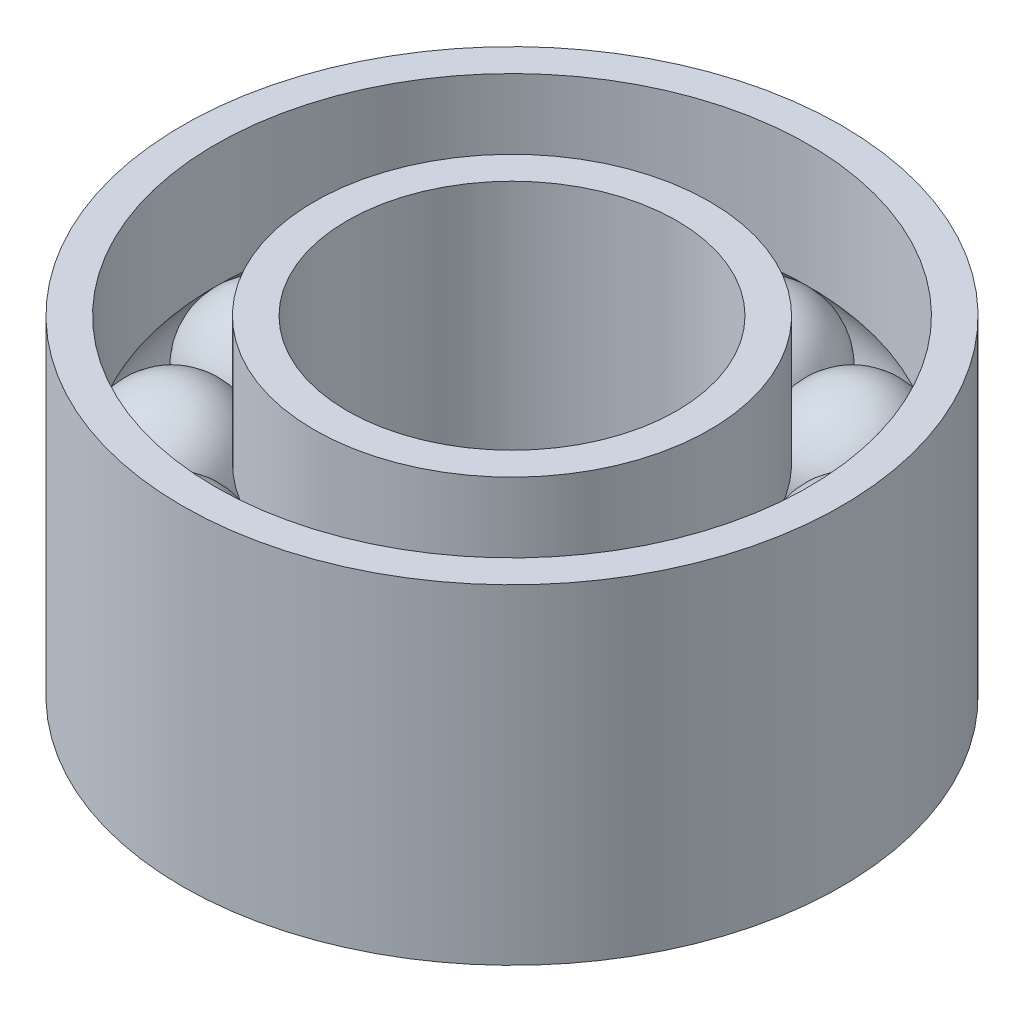
from build123d import *

# Parameters (mm, degrees)
CIRPATTERN3_COUNT = 12


with BuildPart() as part:
    # Sketch2 → Revolve1 (revolve)
    with BuildSketch(Plane.XY):
        with BuildLine():
            Line((-9.600996531, 2.388006937), (-9.600996531, -2.691993063))
            ThreePointArc((-9.600996531, -2.691993063), (-7.060996531, -0.151993063), (-9.600996531, 2.388006937))
        make_face()
    revolve1 = revolve(axis=Axis((-9.600996531, 2.388006937, 0), (0, -1, 0)))

    # CirPattern3: Revolve1 ×12 about axis
    cirpattern3_axis = Axis((0, 0, 0), (0, 1, 0))
    for i in range(1, CIRPATTERN3_COUNT):
        add(revolve1.rotate(cirpattern3_axis, i * 360 / CIRPATTERN3_COUNT))


with BuildPart() as body_2:
    # Sketch1 → Revolve2 (revolve)
    with BuildSketch(Plane.XY):
        with BuildLine():
            Line((-7.62, 6.35), (-6.35, 6.35))
            Line((-6.35, 6.35), (-6.35, -6.35))
            Line((-6.35, -6.35), (-7.62, -6.35))
            Line((-7.62, -6.35), (-7.62, -1.741726607))
            ThreePointArc((-7.62, -1.741726607), (-7.060996531, -0.151993063), (-7.62, 1.437740482))
            Line((-7.62, 1.437740482), (-7.62, 6.35))
        make_face()
        with BuildLine():
            Line((-12.7, 6.35), (-11.43, 6.35))
            Line((-11.43, 6.35), (-11.43, 1.610489933))
            ThreePointArc((-11.43, 1.610489933), (-12.140996531, -0.151993063), (-11.43, -1.914476059))
            Line((-11.43, -1.914476059), (-11.43, -6.35))
            Line((-11.43, -6.35), (-12.7, -6.35))
            Line((-12.7, -6.35), (-12.7, 6.35))
        make_face()
    revolve(axis=Axis((0, 6.985, 0), (0, -1, 0)))


solid = Compound([part.part, body_2.part])
